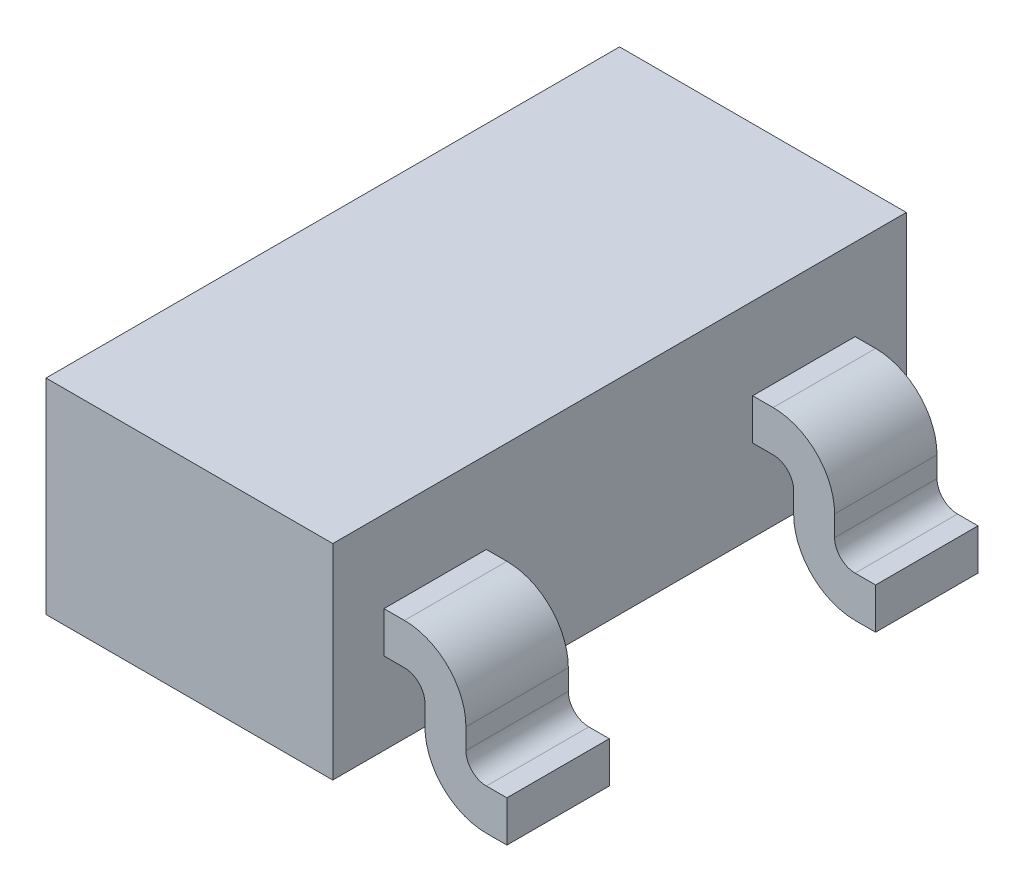
from build123d import *

# Parameters (mm, degrees)
BASES_W    = 1.4
BASES_H    = 2.8
BASE_DEPTH = 0.5
LEG1_DEPTH = 0.25
LEG2_DEPTH = 0.25


with BuildPart() as part:
    # BaseS → Base (new body, symmetric)
    with BuildSketch(Plane(origin=(0, 0, 0), x_dir=(1, 0, 0), z_dir=(0, 1, 0))):
        Rectangle(BASES_W, BASES_H)
    extrude(amount=BASE_DEPTH, both=True)

    # Leg1S → Leg1 (add, symmetric)
    with BuildSketch(Plane.XY):
        with BuildLine():
            Line((-0.7, 0.1), (-0.8, 0.1))
            ThreePointArc((-0.8, 0.1), (-1.012132034, 0.012132034), (-1.1, -0.2))
            Line((-1.1, -0.2), (-1.1, -0.3))
            ThreePointArc((-1.1, -0.3), (-1.129289322, -0.370710678), (-1.2, -0.4))
            Line((-1.2, -0.4), (-1.3, -0.4))
            Line((-1.3, -0.4), (-1.3, -0.6))
            Line((-1.3, -0.6), (-1.2, -0.6))
            ThreePointArc((-1.2, -0.6), (-0.987867966, -0.512132034), (-0.9, -0.3))
            Line((-0.9, -0.3), (-0.9, -0.2))
            ThreePointArc((-0.9, -0.2), (-0.870710678, -0.129289322), (-0.8, -0.1))
            Line((-0.8, -0.1), (-0.7, -0.1))
            Line((-0.7, -0.1), (-0.7, 0.1))
        make_face()
    extrude(amount=LEG1_DEPTH, both=True)

    # Leg2S → Leg2 (add, symmetric)
    with BuildSketch(Plane.XY.offset(0.9)):
        with BuildLine():
            Line((0.7, -0.1), (0.8, -0.1))
            ThreePointArc((0.8, -0.1), (0.870710678, -0.129289322), (0.9, -0.2))
            Line((0.9, -0.2), (0.9, -0.3))
            ThreePointArc((0.9, -0.3), (0.987867966, -0.512132034), (1.2, -0.6))
            Line((1.2, -0.6), (1.3, -0.6))
            Line((1.3, -0.6), (1.3, -0.4))
            Line((1.3, -0.4), (1.2, -0.4))
            ThreePointArc((1.2, -0.4), (1.129289322, -0.370710678), (1.1, -0.3))
            Line((1.1, -0.3), (1.1, -0.2))
            ThreePointArc((1.1, -0.2), (1.012132034, 0.012132034), (0.8, 0.1))
            Line((0.8, 0.1), (0.7, 0.1))
            Line((0.7, 0.1), (0.7, -0.1))
        make_face()
    leg2 = extrude(amount=LEG2_DEPTH, both=True)

    # Leg2M: Leg2 across plane
    add(leg2.mirror(Plane.XY))


solid = part.part
